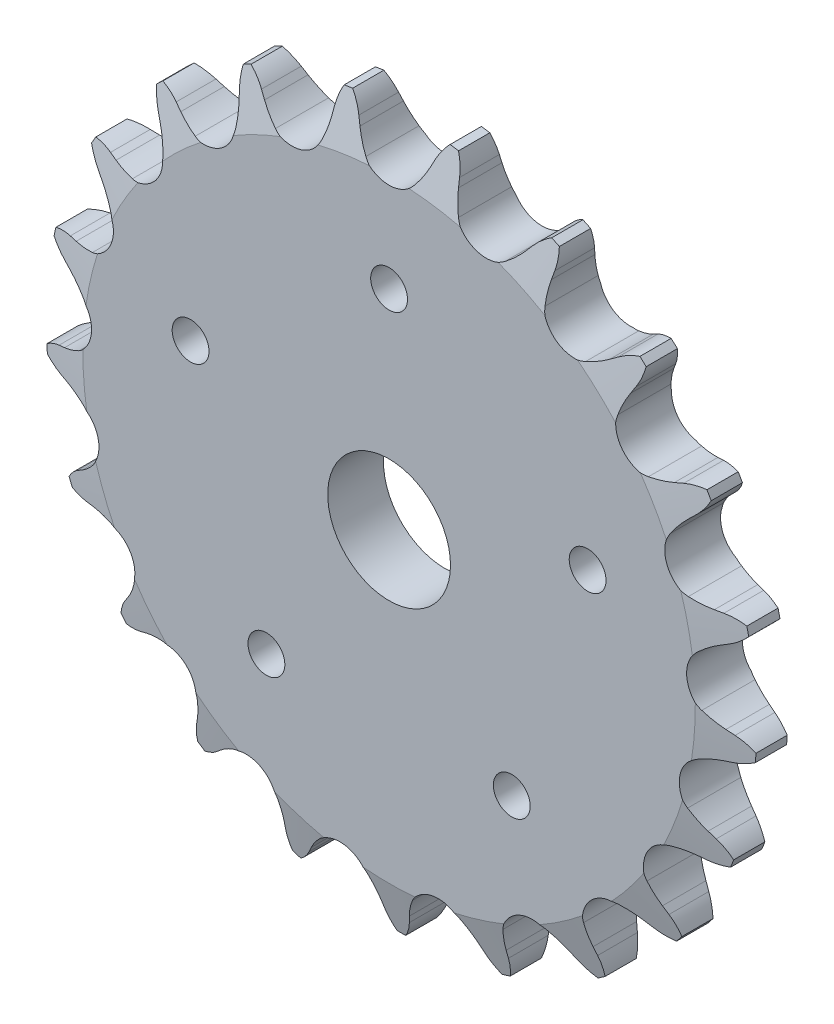
from build123d import *

# Parameters (mm, degrees)
TOOTH_CUT_NUMBER_OF_TEETH_21_DEPTH = 66.068301236
TOOTH_PATTERN_21_21_COUNT          = 21
SKETCH3_W                          = 18.1864
SKETCH3_H                          = 34.925
CUT_EXTRUDE1_DEPTH                 = 69.465325979
CUT_EXTRUDE1_DEPTH_BACK            = 69.465325979
SKETCH4_R                          = 7.9375
CUT_EXTRUDE2_DEPTH                 = 76.2
SKETCH9_R                          = 2.38125
CUT_EXTRUDE5_DEPTH                 = 66.303853803
CIRPATTERN2_COUNT                  = 5


with BuildPart() as part:
    # Sprocket-BaseSketch → 40 _08A_ ANSI _ISO_ Chain Number_ 3.355i (revolve)
    with BuildSketch(Plane(origin=(0, 0, 0), x_dir=(0, 0, -1), z_dir=(1, 0, 0))):
        Polygon((3.6068, 0), (3.6068, 39.589497274), (2.0193, 45.939497274), (-2.0193, 45.939497274), (-3.6068, 39.589497274), (-3.6068, 0), align=None)
    revolve(axis=Axis((0, 0, -14.4272), (0, 0, 1)))

    # Tooth-Sketch → Tooth-Cut_ Number of teeth_ 21 (cut, symmetric)
    with BuildSketch(Plane.XY):
        with BuildLine():
            Line((4.564305527, 42.527455117), (4.946850907, 43.449916944))
            ThreePointArc((4.946850907, 43.449916944), (7.348832238, 46.374880247), (10.970801144, 47.473181609))
            ThreePointArc((10.970801144, 47.473181609), (0, 48.724341451), (-10.970801144, 47.473181609))
            ThreePointArc((-10.970801144, 47.473181609), (-7.348832238, 46.374880247), (-4.946850907, 43.449916944))
            Line((-4.946850907, 43.449916944), (-4.564305527, 42.527455117))
            ThreePointArc((-4.564305527, 42.527455117), (-3.949305935, 41.286216115), (-3.174210598, 40.13811944))
            ThreePointArc((-3.174210598, 40.13811944), (0, 38.585051988), (3.174210598, 40.13811944))
            ThreePointArc((3.174210598, 40.13811944), (3.949305935, 41.286216115), (4.564305527, 42.527455117))
        make_face()
    tooth_cut_number_of_teeth_21 = extrude(amount=TOOTH_CUT_NUMBER_OF_TEETH_21_DEPTH, both=True, mode=Mode.SUBTRACT)

    # Tooth Pattern_ 21 _ 21: Tooth-Cut_ Number of teeth_ 21 ×21 about axis
    tooth_pattern_21_21_axis = Axis((0, 0, -88.99), (0, 0, 1))
    for i in range(1, TOOTH_PATTERN_21_21_COUNT):
        add(tooth_cut_number_of_teeth_21.rotate(tooth_pattern_21_21_axis, i * 360 / TOOTH_PATTERN_21_21_COUNT), mode=Mode.SUBTRACT)

    # Sketch3 → Hub-Revolve1 (revolve)
    with BuildSketch(Plane(origin=(0, 0, 0), x_dir=(0, 0, -1), z_dir=(1, 0, 0))):
        with Locations((12.7, 17.4625)):
            Rectangle(SKETCH3_W, SKETCH3_H)
    revolve(axis=Axis((0, 0, 18.1864), (0, 0, -1)))

    # Sketch4 → Cut-Extrude1 (cut, two sides: drawn at the far end of the back side and taken through both)
    with BuildSketch(Plane.XY.offset(-CUT_EXTRUDE1_DEPTH_BACK)):
        Circle(SKETCH4_R)
    extrude(amount=CUT_EXTRUDE1_DEPTH + CUT_EXTRUDE1_DEPTH_BACK, mode=Mode.SUBTRACT)

    # Sketch6 → Cut-Extrude2 (cut, symmetric)
    with BuildSketch(Plane(origin=(0, 0, 0), x_dir=(0, 0, -1), z_dir=(1, 0, 0))):
        Polygon((63.424912673, -76.2), (63.424912673, 76.2), (3.6068, 76.2), (3.6068, 34.925), (3.6068, -34.925), (3.6068, -76.2), align=None)
    extrude(amount=CUT_EXTRUDE2_DEPTH, both=True, mode=Mode.SUBTRACT)

    # Sketch9 → Cut-Extrude5 (cut, through all)
    with BuildSketch(Plane.XY.offset(3.6068)):
        with Locations((0, 26.9875)):
            Circle(SKETCH9_R)
    cut_extrude5 = extrude(amount=-CUT_EXTRUDE5_DEPTH, mode=Mode.SUBTRACT)

    # CirPattern2: Cut-Extrude5 ×5 about axis
    cirpattern2_axis = Axis((0, 0, -88.99), (0, 0, 1))
    for i in range(1, CIRPATTERN2_COUNT):
        add(cut_extrude5.rotate(cirpattern2_axis, i * 360 / CIRPATTERN2_COUNT), mode=Mode.SUBTRACT)


solid = part.part
